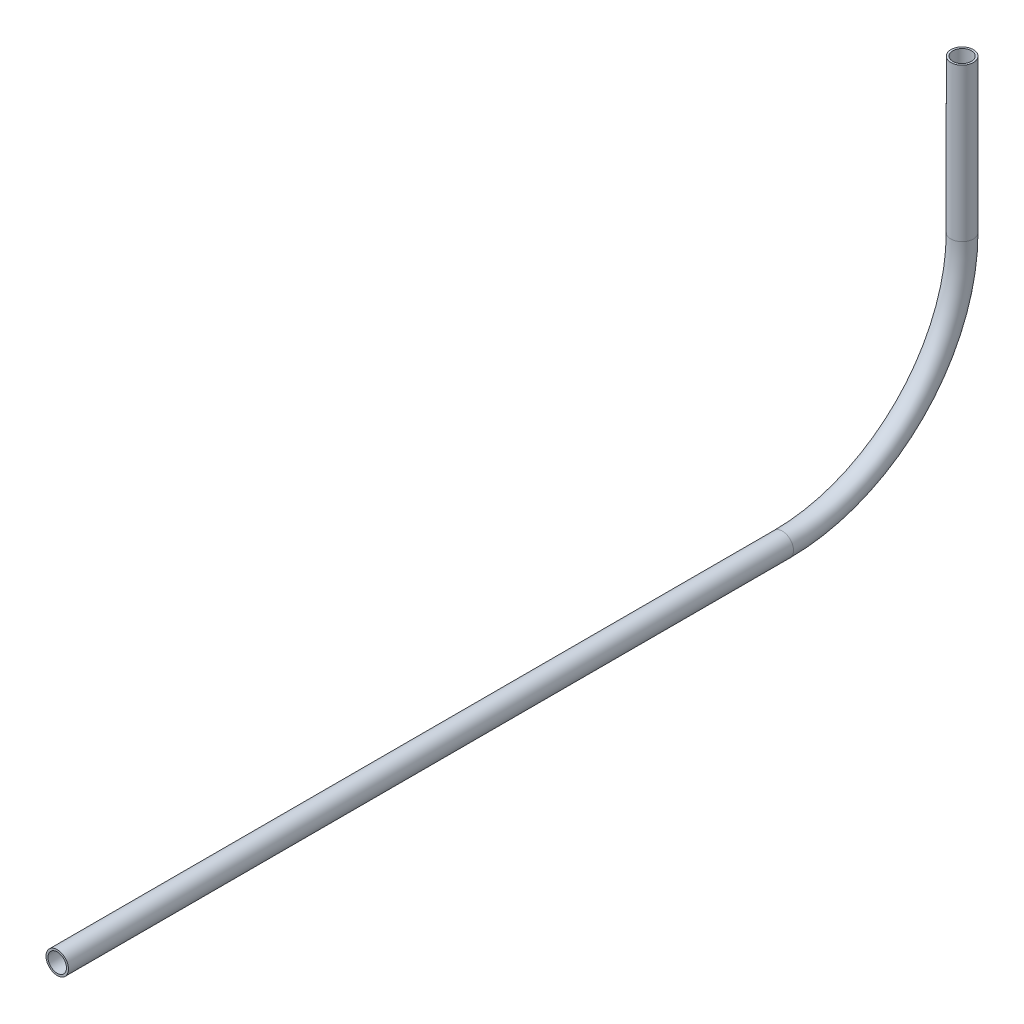
from build123d import *

# Parameters (mm, degrees)
SKETCH11_R                = 3.175
SKETCH11_R_2              = 2.6162
PIPE_0_5_SCH_40_1_DEPTH   = 204.830262489
SKETCH11_ON_SEGMENT_2_R   = 3.175
SKETCH11_ON_SEGMENT_2_R_2 = 2.6162
PIPE_0_5_SCH_40_1_2_ANGLE = 90
SKETCH11_ON_SEGMENT_3_R   = 3.175
SKETCH11_ON_SEGMENT_3_R_2 = 2.6162
PIPE_0_5_SCH_40_1_3_DEPTH = 43.174908852


with BuildPart() as part:
    # Sketch11 → Pipe 0.5 SCH 40(1) (new body)
    with BuildSketch(Plane(origin=(0, 165.169649272, 258.995340328), x_dir=(0, 1, 0), z_dir=(0, 0, -1))):
        Circle(SKETCH11_R)
        Circle(SKETCH11_R_2, mode=Mode.SUBTRACT)
    extrude(amount=PIPE_0_5_SCH_40_1_DEPTH)


with BuildPart() as body_2:
    # Sketch11 on segment 2 (carried to the start of arc 2) → Pipe 0.5 SCH 40_1 2 (revolve)
    with BuildSketch(Plane(origin=(0, 165.169649272, 54.165077838), x_dir=(0, 1, 0), z_dir=(0, 0, -1))):
        Circle(SKETCH11_ON_SEGMENT_2_R)
        Circle(SKETCH11_ON_SEGMENT_2_R_2, mode=Mode.SUBTRACT)
    revolve(axis=Axis((0, 215.969649272, 54.165077838), (1, 0, 0)), revolution_arc=PIPE_0_5_SCH_40_1_2_ANGLE)


with BuildPart() as body_3:
    # Sketch11 on segment 3 (carried to segment 3) → Pipe 0.5 SCH 40_1 3 (new body)
    with BuildSketch(Plane(origin=(0, 215.969649272, 3.365077838), x_dir=(0, 0, 1), z_dir=(0, 1, 0))):
        Circle(SKETCH11_ON_SEGMENT_3_R)
        Circle(SKETCH11_ON_SEGMENT_3_R_2, mode=Mode.SUBTRACT)
    extrude(amount=PIPE_0_5_SCH_40_1_3_DEPTH)


solid = Compound([part.part, body_2.part, body_3.part])
